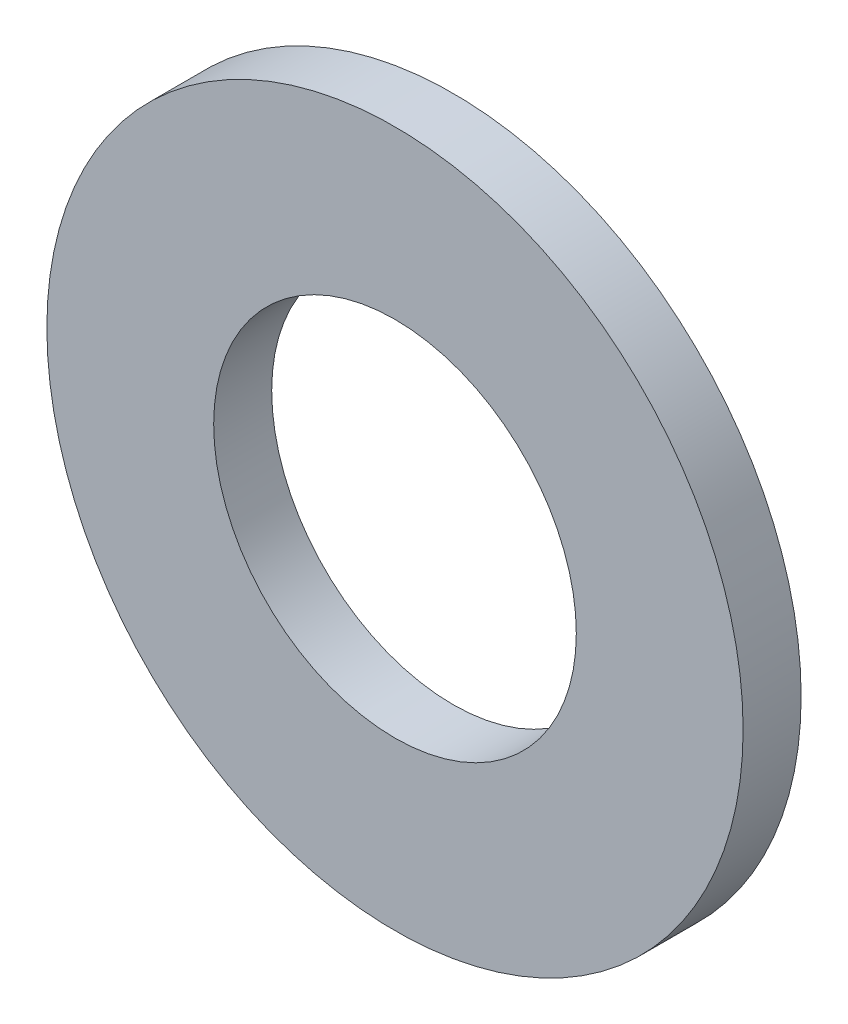
from build123d import *

# Parameters (mm, degrees)
SKETCH1_R           = 6
SKETCH1_R_2         = 3.125
BOSS_EXTRUDE1_DEPTH = 1


with BuildPart() as part:
    # Sketch1 → Boss-Extrude1 (new body)
    with BuildSketch(Plane.XY):
        Circle(SKETCH1_R)
        Circle(SKETCH1_R_2, mode=Mode.SUBTRACT)
    extrude(amount=BOSS_EXTRUDE1_DEPTH)


solid = part.part
